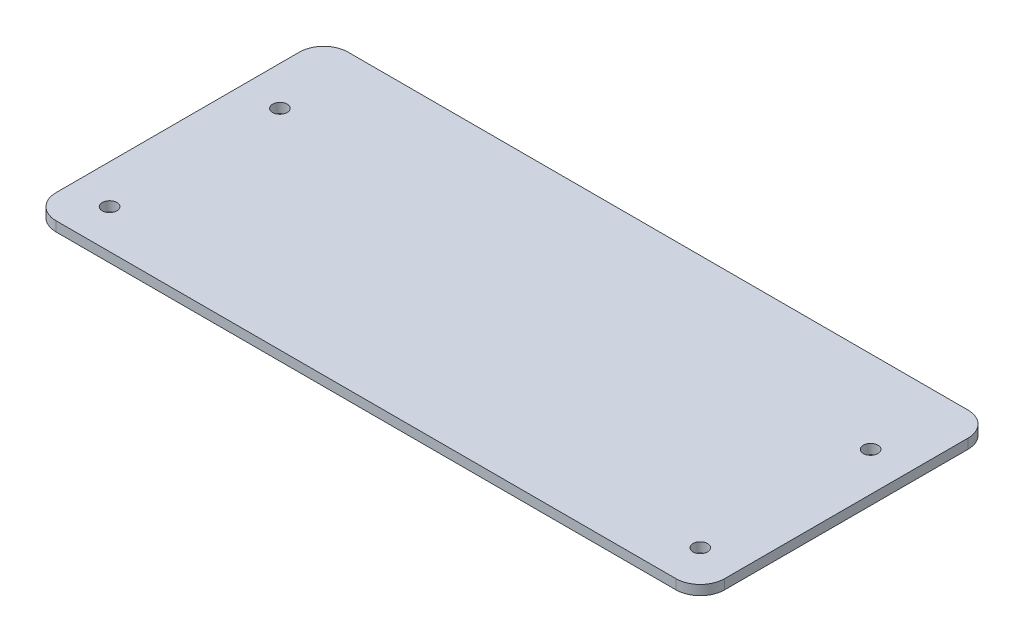
from build123d import *

# Parameters (mm, degrees)
BOSS_EXTRUDE1_DEPTH = 2
SKETCH4_R           = 1.5
CUT_EXTRUDE1_DEPTH  = 3


with BuildPart() as part:
    # Sketch1 → Boss-Extrude1 (new body)
    with BuildSketch(Plane(origin=(0, 0, 0), x_dir=(1, 0, 0), z_dir=(0, 1, 0))):
        with BuildLine():
            Line((-687.300884956, 62.644247788), (-814.660884956, 62.644247788))
            ThreePointArc((-814.660884956, 62.644247788), (-818.196418862, 61.179781694), (-819.660884956, 57.644247788))
            Line((-819.660884956, 57.644247788), (-819.660884956, 7.644247788))
            ThreePointArc((-819.660884956, 7.644247788), (-818.196418862, 4.108713882), (-814.660884956, 2.644247788))
            Line((-814.660884956, 2.644247788), (-687.300884956, 2.644247788))
            ThreePointArc((-687.300884956, 2.644247788), (-683.76535105, 4.108713882), (-682.300884956, 7.644247788))
            Line((-682.300884956, 7.644247788), (-682.300884956, 57.644247788))
            ThreePointArc((-682.300884956, 57.644247788), (-683.76535105, 61.179781694), (-687.300884956, 62.644247788))
        make_face()
    extrude(amount=BOSS_EXTRUDE1_DEPTH)

    # Sketch4 → Cut-Extrude1 (cut, through all)
    with BuildSketch(Plane.XZ):
        with Locations((-811.660884956, -10.644247788)):
            Circle(SKETCH4_R)
        with Locations((-811.660884956, -45.644247788)):
            Circle(SKETCH4_R)
        with Locations((-690.300884956, -10.644247788)):
            Circle(SKETCH4_R)
        with Locations((-690.300884956, -45.644247788)):
            Circle(SKETCH4_R)
    extrude(amount=-CUT_EXTRUDE1_DEPTH, mode=Mode.SUBTRACT)


solid = part.part
